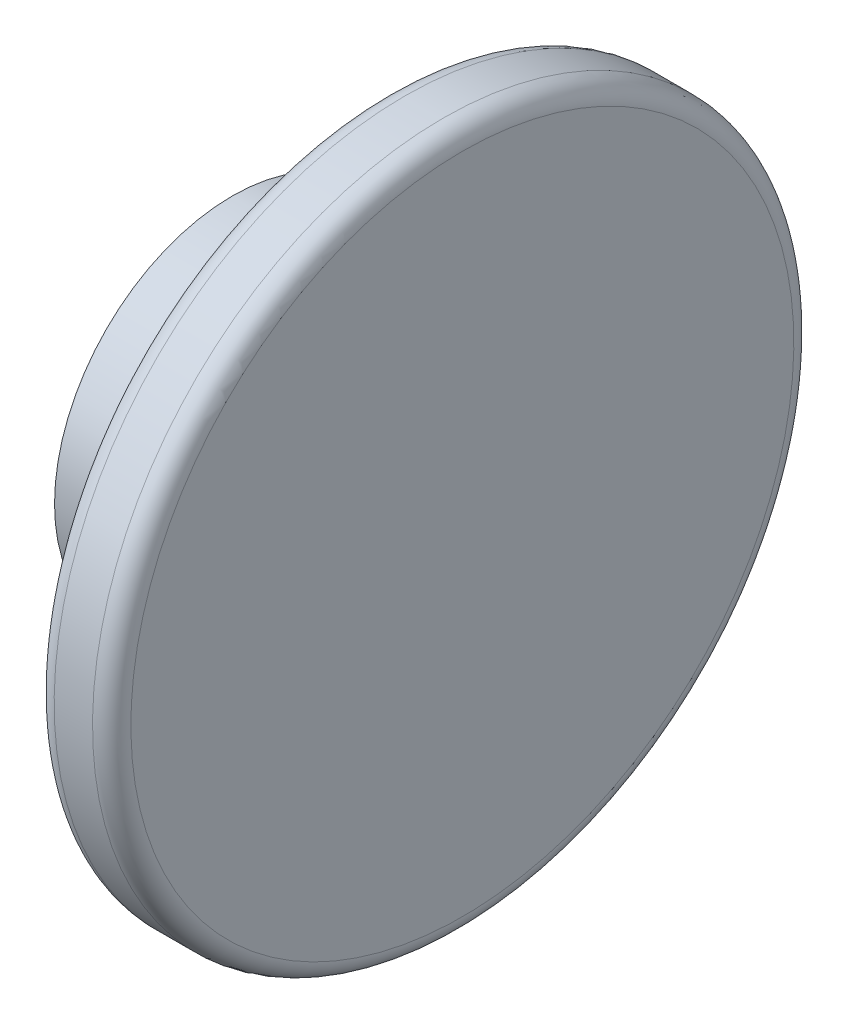
from build123d import *

# Parameters (mm, degrees)
SKETCH1_W           = 17.995
SKETCH1_H           = 18.542
SKETCH2_R           = 3.71475
CUT_EXTRUDE1_DEPTH  = 8.5725
CUT_EXTRUDE1_TAPER  = 3
SKETCH3_R           = 36.576
BOSS_EXTRUDE1_DEPTH = 8
FILLET1_R           = 2
SKETCH4_R           = 18.542
SKETCH4_R_2         = 12.7
CUT_EXTRUDE2_DEPTH  = 2
FILLET2_R           = 5


with BuildPart() as part:
    # Sketch1 → Revolve1 (revolve)
    with BuildSketch(Plane.XY):
        with Locations((17.2525, 9.271)):
            Rectangle(SKETCH1_W, SKETCH1_H)
    revolve(axis=Axis((8.255, 0, 0), (1, 0, 0)))

    # Sketch2 → Cut-Extrude1 (cut)
    with BuildSketch(Plane.ZY.offset(-8.255)):
        Circle(SKETCH2_R)
    extrude(amount=-CUT_EXTRUDE1_DEPTH, taper=CUT_EXTRUDE1_TAPER, mode=Mode.SUBTRACT)

    # Sketch3 → Boss-Extrude1 (add)
    with BuildSketch(Plane(origin=(26.25, 0, 0), x_dir=(0, 0, -1), z_dir=(1, 0, 0))):
        Circle(SKETCH3_R)
    extrude(amount=BOSS_EXTRUDE1_DEPTH)

    # Fillet1
    fillet1_edges = [part.edges().sort_by_distance(p)[0] for p in [
        (26.25, -18.542, 0),
        (26.25, 0, 36.576),
        (34.25, 0, 36.576),
    ]]
    fillet(fillet1_edges, radius=FILLET1_R)

    # Sketch4 → Cut-Extrude2 (cut)
    with BuildSketch(Plane.ZY.offset(-8.255)):
        Circle(SKETCH4_R)
        Circle(SKETCH4_R_2, mode=Mode.SUBTRACT)
    extrude(amount=-CUT_EXTRUDE2_DEPTH, mode=Mode.SUBTRACT)

    # Sketch5 → Revolve2 (revolve)
    with BuildSketch(Plane(origin=(0, 0, 0), x_dir=(1, 0, 0), z_dir=(0, 1, 0))):
        Polygon((8.255, -12.7), (10.255, -18.542), (10.255, -12.7), align=None)
    revolve(axis=Axis((0, 0, 0), (1, 0, 0)))

    # Fillet2
    fillet2_edges = [part.edges().sort_by_distance(p)[0] for p in [
        (8.255, 0, -12.7),
    ]]
    fillet(fillet2_edges, radius=FILLET2_R)


solid = part.part
